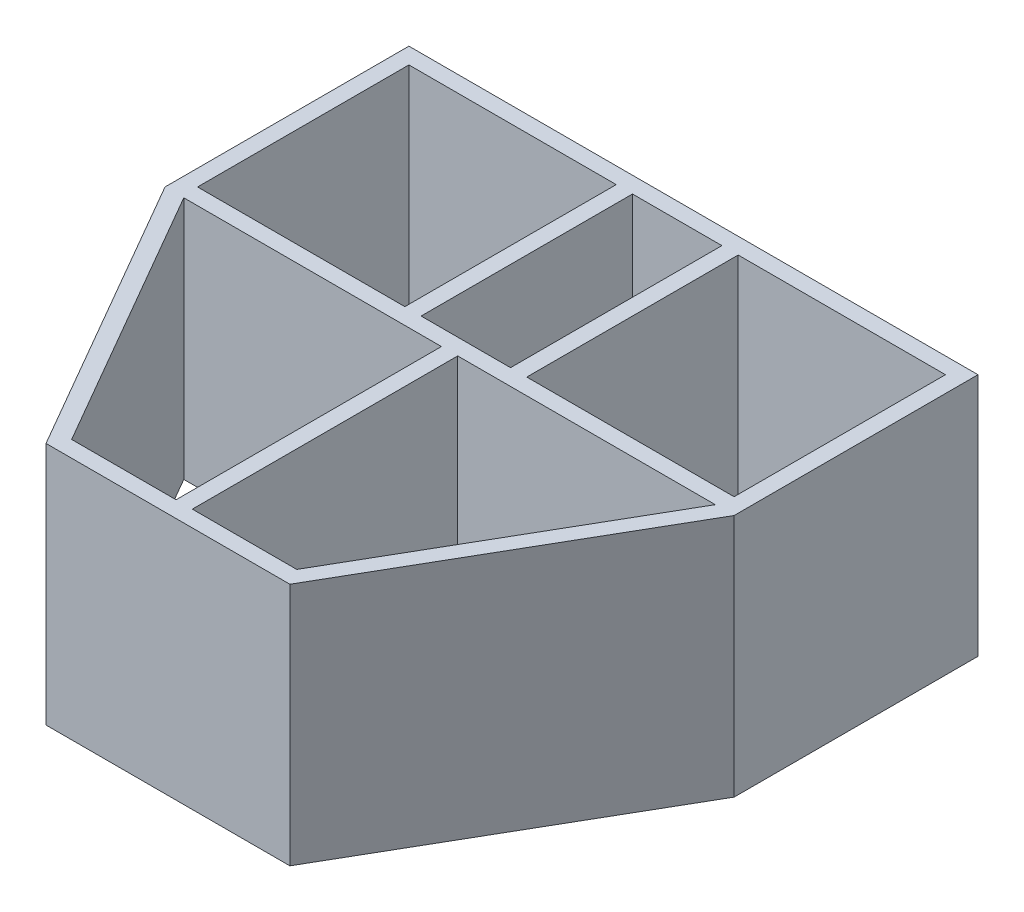
from build123d import *

# Parameters (mm, degrees)
SFIVEBASETP1_W     = 12.75
SFIVEBASETP1_H     = 13
SFIVEBASETP1_W_2   = 5.5
FFIVEBASETP1_DEPTH = 15


with BuildPart() as part:
    # SFiveBaseTP1 → FFiveBaseTP1 (new body)
    with BuildSketch(Plane(origin=(0, 0, 0), x_dir=(1, 0, 0), z_dir=(0, 1, 0))):
        Polygon((-17.5, 15), (17.5, 15), (17.5, 0), (7.5, -17.320508076), (-7.5, -17.320508076), (-17.5, 0), align=None)
        Polygon((-16.345299462, 0), (-6.922649731, -16.320508076), (-0.5, -16.320508076), (-0.5, 0), align=None, mode=Mode.SUBTRACT)
        with Locations((-10.125, 7.5)):
            Rectangle(SFIVEBASETP1_W, SFIVEBASETP1_H, mode=Mode.SUBTRACT)
        with Locations((10.125, 7.5)):
            Rectangle(SFIVEBASETP1_W, SFIVEBASETP1_H, mode=Mode.SUBTRACT)
        Polygon((0.5, 0), (0.5, -16.320508076), (6.922649731, -16.320508076), (16.345299462, 0), align=None, mode=Mode.SUBTRACT)
        with Locations((0, 7.5)):
            Rectangle(SFIVEBASETP1_W_2, SFIVEBASETP1_H, mode=Mode.SUBTRACT)
    extrude(amount=FFIVEBASETP1_DEPTH)


solid = part.part
